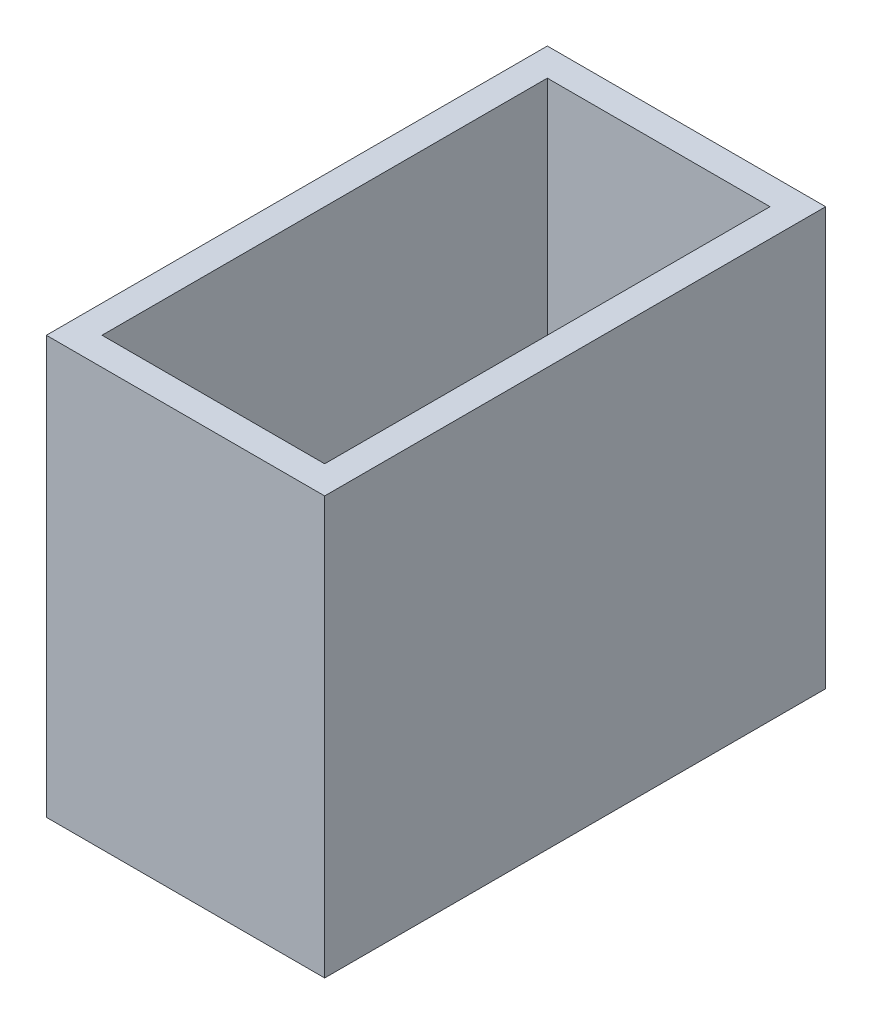
from build123d import *

# Parameters (mm, degrees)
SUSBBASE_W     = 10
SUSBBASE_H     = 18
SUSBBASE_W_2   = 8
SUSBBASE_H_2   = 16
FUSBBASE_DEPTH = 15


with BuildPart() as part:
    # SUsbBase → FUsbBase (new body)
    with BuildSketch(Plane(origin=(0, 0, 0), x_dir=(1, 0, 0), z_dir=(0, 1, 0))):
        Rectangle(SUSBBASE_W, SUSBBASE_H)
        Rectangle(SUSBBASE_W_2, SUSBBASE_H_2, mode=Mode.SUBTRACT)
    extrude(amount=FUSBBASE_DEPTH)


solid = part.part
